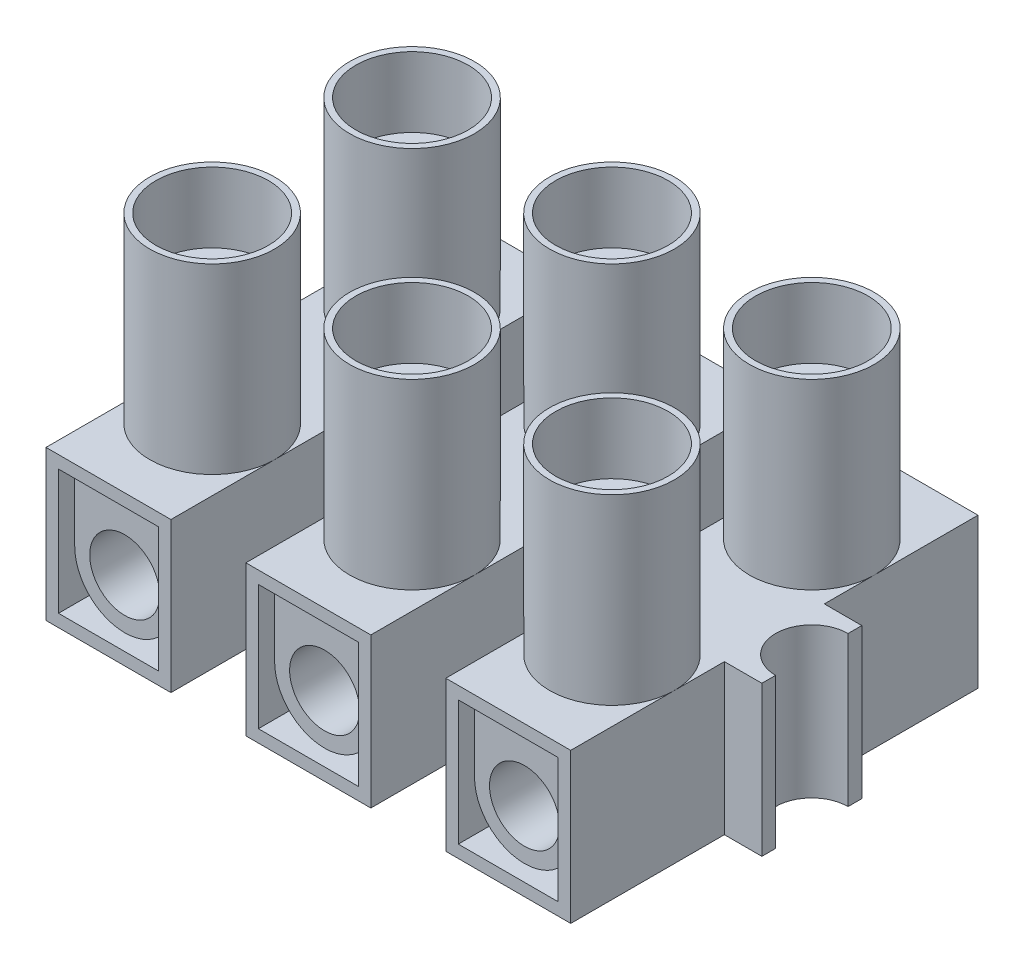
from build123d import *
from build123d.topology import SkipClean

# Parameters (mm, degrees)
ESQUISSE1_W                  = 5
ESQUISSE1_H                  = 6
ESQUISSE1_W_2                = 4
ESQUISSE1_H_2                = 5
BOSS_EXTRU_1_DEPTH           = 8.15
BOSS_EXTRU_2_START           = -6
ESQUISSE2_R                  = 2.5
ESQUISSE2_R_2                = 2.25
BOSS_EXTRU_2_DEPTH           = 7.3
BOSS_EXTRU_3_DEPTH           = 6
ESQUISSE4_R                  = 1.4
BOSS_EXTRU_4_DEPTH           = 7.5
ESQUISSE5_R                  = 2
ENL_V_MAT_EXTRU_1_DEPTH      = 0.5
TROU_TARAUD_M2_51_AT_2_COUNT = 2
TROU_TARAUD_M2_51_AT_2_PITCH = 8
ESQUISSE9_W                  = 0.6
ESQUISSE9_H                  = 0.6
ENL_V_MAT_EXTRU_2_DEPTH      = 5
ENL_V_MAT_EXTRU_2_DEPTH_BACK = 5
R_P_TITION_LIN_AIRE1_COUNT   = 3
R_P_TITION_LIN_AIRE1_PITCH   = 8


with BuildPart() as part:
    # Esquisse1 → Boss.-Extru.1 (new body, symmetric)
    with BuildSketch(Plane.XY):
        Rectangle(ESQUISSE1_W, ESQUISSE1_H)
        Rectangle(ESQUISSE1_W_2, ESQUISSE1_H_2, mode=Mode.SUBTRACT)
    extrude(amount=BOSS_EXTRU_1_DEPTH, both=True)

    # Esquisse2 → Boss.-Extru.2 (add)
    with BuildSketch(Plane.XZ.offset(3).offset(BOSS_EXTRU_2_START)):
        with Locations((0, 4)):
            Circle(ESQUISSE2_R)
        with Locations(Location((0, 4, 0), (0, 0, 270))):  # turned: the seam where the file's is
            Circle(ESQUISSE2_R_2, mode=Mode.SUBTRACT)
        with Locations((0, -4)):
            Circle(ESQUISSE2_R)
        with Locations(Location((0, -4, 0), (0, 0, 270))):  # turned: the seam where the file's is
            Circle(ESQUISSE2_R_2, mode=Mode.SUBTRACT)
    extrude(amount=-BOSS_EXTRU_2_DEPTH)

    # Esquisse3 → Boss.-Extru.3 (add)
    with BuildSketch(Plane(origin=(0, 3, 0), x_dir=(1, 0, 0), z_dir=(0, 1, 0))):
        with BuildLine():
            Line((-2.5, 2), (-4, 2))
            Line((-4, 2), (-4, 1.45))
            ThreePointArc((-4, 1.45), (-2.55, 0), (-4, -1.45))
            Line((-4, -1.45), (-4, -2))
            Line((-4, -2), (-2.5, -2))
            Line((-2.5, -2), (-2.5, 2))
        make_face()
    boss_extru_3 = extrude(amount=-BOSS_EXTRU_3_DEPTH)

    # Symétrie1: Boss.-Extru.3 across plane
    add(boss_extru_3.mirror(Plane(origin=(0, 0, 0), x_dir=(0, 0, 1), z_dir=(1, 0, 0))))

    # Esquisse5 → Enlèv. mat.-Extru.1 (cut)
    with BuildSketch(Plane(origin=(0, 3, 0), x_dir=(1, 0, 0), z_dir=(0, 1, 0))):
        with Locations(Location((0, -4, 0), (0, 0, 270))):  # turned: the seam where the file's is
            Circle(ESQUISSE5_R)
        with Locations(Location((0, 4, 0), (0, 0, 270))):  # turned: the seam where the file's is
            Circle(ESQUISSE5_R)
    extrude(amount=-ENL_V_MAT_EXTRU_1_DEPTH, mode=Mode.SUBTRACT)


with BuildPart() as body_2:
    # Esquisse4 → Boss.-Extru.4 (new body, symmetric)
    with BuildSketch(Plane.XY):
        with BuildLine():
            Line((-2, 2.5), (-2, -0.5))
            ThreePointArc((-2, -0.5), (0, -2.5), (2, -0.5))
            Line((2, -0.5), (2, 2.5))
            Line((2, 2.5), (-2, 2.5))
        make_face()
        with Locations((0, -0.5)):
            Circle(ESQUISSE4_R, mode=Mode.SUBTRACT)
    extrude(amount=BOSS_EXTRU_4_DEPTH, both=True)

    # Esquisse6 → Trou taraudé M2.51 (revolve, cut)
    with BuildSketch(Plane(origin=(0, 2.5, 4), x_dir=(0, 0, 1), z_dir=(1, 0, 0))):
        Polygon((0, 0), (0, 3.115882135), (1.025, 2.5), (1.025, 0), align=None)
    trou_taraud_m2_51 = revolve(axis=Axis((0, 8.85, 4), (0, -1, 0)), mode=Mode.SUBTRACT)

    # Trou taraudé M2.51 at 2: Trou taraudé M2.51 ×2
    with Locations(*[(0, 0, -i * TROU_TARAUD_M2_51_AT_2_PITCH) for i in range(1, TROU_TARAUD_M2_51_AT_2_COUNT)]):
        add(trou_taraud_m2_51, mode=Mode.SUBTRACT)


with BuildPart() as body_3:
    # Esquisse8 → Révolution1 (revolve)
    with BuildSketch(Plane(origin=(0, 0, 0), x_dir=(0, 0, -1), z_dir=(1, 0, 0))):
        Polygon((-4, 7.5), (-4, 0.5), (-5.3, 0.5), (-5.3, 5.5), (-6.25, 5.5), (-6.25, 7.5), align=None)
    revolve(axis=Axis((0, 7.5, 4), (0, -1, 0)))

    # Esquisse9 → Enlèv. mat.-Extru.2 (cut, two sides)
    with BuildSketch(Plane(origin=(0, 0, 0), x_dir=(0, 0, -1), z_dir=(1, 0, 0))) as enl_v_mat_extru_2_sk:
        with Locations((-4, 7.2)):
            Rectangle(ESQUISSE9_W, ESQUISSE9_H)
    extrude(amount=ENL_V_MAT_EXTRU_2_DEPTH, mode=Mode.SUBTRACT)
    extrude(enl_v_mat_extru_2_sk.sketch, amount=-ENL_V_MAT_EXTRU_2_DEPTH_BACK, mode=Mode.SUBTRACT)


with BuildPart() as body_4:
    # Symétrie3: mirrored copy
    add(body_3.part.mirror(Plane.XY))


with BuildPart() as r_p_tition_lin_aire1_1:
    # Répétition linéaire1: pattern copy
    add(body_4.part.moved(Location(Vector(1, 0, 0) * (1 * R_P_TITION_LIN_AIRE1_PITCH))))


with BuildPart() as r_p_tition_lin_aire1_2:
    # Répétition linéaire1: pattern copy
    add(body_4.part.moved(Location(Vector(1, 0, 0) * (2 * R_P_TITION_LIN_AIRE1_PITCH))))


with BuildPart() as r_p_tition_lin_aire1_3:
    # Répétition linéaire1: pattern copy
    add(body_3.part.moved(Location(Vector(1, 0, 0) * (1 * R_P_TITION_LIN_AIRE1_PITCH))))


with BuildPart() as r_p_tition_lin_aire1_4:
    # Répétition linéaire1: pattern copy
    add(body_3.part.moved(Location(Vector(1, 0, 0) * (2 * R_P_TITION_LIN_AIRE1_PITCH))))


with BuildPart() as r_p_tition_lin_aire1_5:
    # Répétition linéaire1: pattern copy
    add(body_2.part.moved(Location(Vector(1, 0, 0) * (1 * R_P_TITION_LIN_AIRE1_PITCH))))


with BuildPart() as r_p_tition_lin_aire1_6:
    # Répétition linéaire1: pattern copy
    add(body_2.part.moved(Location(Vector(1, 0, 0) * (2 * R_P_TITION_LIN_AIRE1_PITCH))))


with BuildPart() as r_p_tition_lin_aire1_7:
    # Répétition linéaire1: pattern copy
    add(part.part.moved(Location(Vector(1, 0, 0) * (1 * R_P_TITION_LIN_AIRE1_PITCH))))


with BuildPart() as r_p_tition_lin_aire1_8:
    # Répétition linéaire1: pattern copy
    add(part.part.moved(Location(Vector(1, 0, 0) * (2 * R_P_TITION_LIN_AIRE1_PITCH))))


with BuildPart() as part_1:
    add(part.part)

    # Combiner1: union Répétition linéaire1_7, Répétition linéaire1_8
    add(r_p_tition_lin_aire1_7.part)
    add(r_p_tition_lin_aire1_8.part)


solid = Compound([body_2.part, body_3.part, body_4.part, r_p_tition_lin_aire1_1.part, r_p_tition_lin_aire1_2.part, r_p_tition_lin_aire1_3.part, r_p_tition_lin_aire1_4.part, r_p_tition_lin_aire1_5.part, r_p_tition_lin_aire1_6.part, part_1.part])
